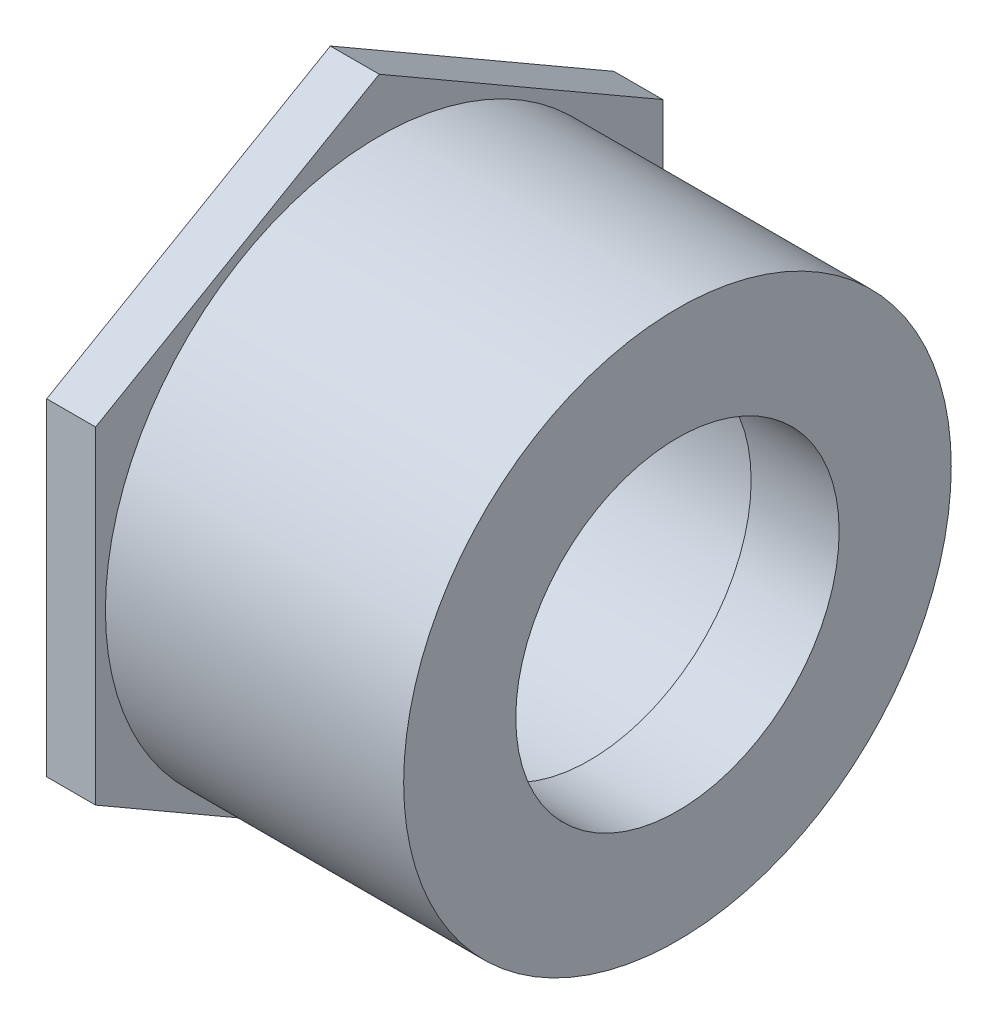
from build123d import *

# Parameters (mm, degrees)
SKETCH2_R           = 30.3149
BOSS_EXTRUDE1_DEPTH = 7.9375


with BuildPart() as part:
    # Sketch1 → Revolve1 (revolve)
    with BuildSketch(Plane.XY):
        Polygon((-56.35625, -44.45), (0, -44.45), (0, -26.2509), (-14.2875, -26.2509), (-14.2875, -30.0863), (-56.35625, -30.3149), align=None)
    revolve(axis=Axis((-56.35625, 0, 0), (1, 0, 0)))

    # Sketch2 → Boss-Extrude1 (add)
    with BuildSketch(Plane.ZY.offset(56.35625)):
        Polygon((0, 53.159526036), (-46.0375, 26.579763018), (-46.0375, -26.579763018), (0, -53.159526036), (46.0375, -26.579763018), (46.0375, 26.579763018), align=None)
        Circle(SKETCH2_R, mode=Mode.SUBTRACT)
    extrude(amount=-BOSS_EXTRUDE1_DEPTH)


solid = part.part
